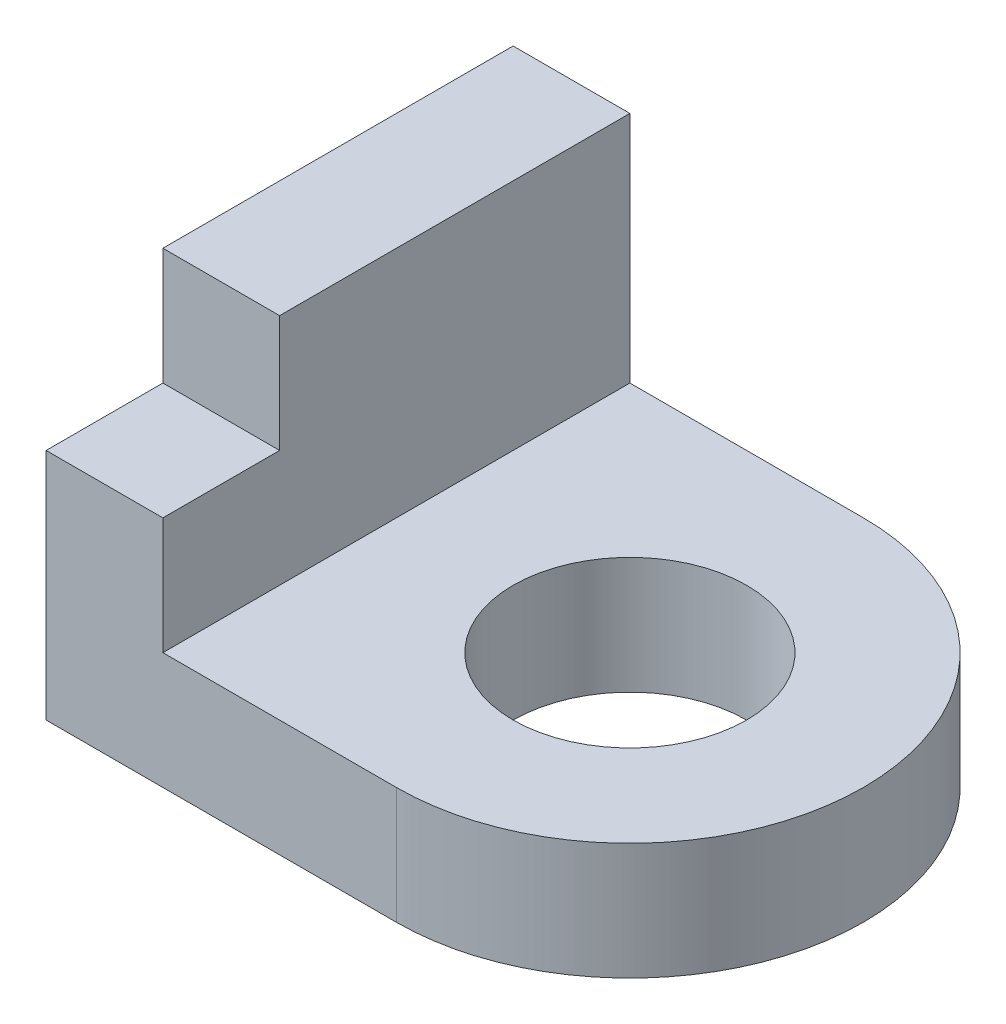
from build123d import *

# Parameters (mm, degrees)
SKETCH_1_R      = 5
EXTRUDE_1_DEPTH = 5
SKETCH_1_3_W    = 5
SKETCH_1_3_H    = 5
EXTRUDE_2_DEPTH = 10
SKETCH_1_4_W    = 5
SKETCH_1_4_H    = 15
EXTRUDE_3_DEPTH = 15


with BuildPart() as part:
    # 草圖1 → 填料-伸長1 (new body)
    with BuildSketch(Plane(origin=(0, 0, 0), x_dir=(1, 0, 0), z_dir=(0, 1, 0))):
        with BuildLine():
            ThreePointArc((0, -10), (10, 0), (0, 10))
            Line((0, 10), (-10, 10))
            Line((-10, 10), (-10, -5))
            Line((-10, -5), (-10, -10))
            Line((-10, -10), (0, -10))
        make_face()
        Circle(SKETCH_1_R, mode=Mode.SUBTRACT)
    extrude(amount=EXTRUDE_1_DEPTH)

    # 草圖1<3> → 填料-伸長2 (add)
    with BuildSketch(Plane(origin=(0, 0, 0), x_dir=(1, 0, 0), z_dir=(0, 1, 0))):
        with Locations((-12.5, -7.5)):
            Rectangle(SKETCH_1_3_W, SKETCH_1_3_H)
    extrude(amount=EXTRUDE_2_DEPTH)

    # 草圖1<4> → 填料-伸長3 (add)
    with BuildSketch(Plane(origin=(0, 0, 0), x_dir=(1, 0, 0), z_dir=(0, 1, 0))):
        with Locations((-12.5, 2.5)):
            Rectangle(SKETCH_1_4_W, SKETCH_1_4_H)
    extrude(amount=EXTRUDE_3_DEPTH)


solid = part.part
